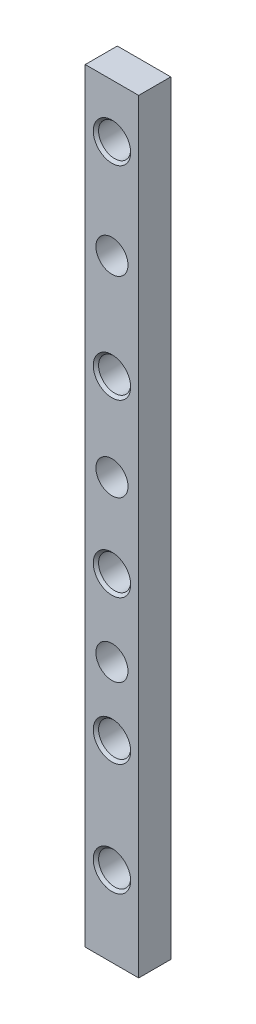
from build123d import *

# Parameters (mm, degrees)
SKETCH1_W           = 10
SKETCH1_H           = 143
SKETCH1_R           = 3
BOSS_EXTRUDE1_DEPTH = 6
CHAMFER1_SIZE       = 0.5


with BuildPart() as part:
    # Sketch1 → Boss-Extrude1 (new body)
    with BuildSketch(Plane.XY):
        Rectangle(SKETCH1_W, SKETCH1_H)
        with Locations((0, -56.5)):
            Circle(SKETCH1_R, mode=Mode.SUBTRACT)
        with Locations((0, -35.5)):
            Circle(SKETCH1_R, mode=Mode.SUBTRACT)
        with Locations((0, -8.5)):
            Circle(SKETCH1_R, mode=Mode.SUBTRACT)
        with Locations((0, 23.5)):
            Circle(SKETCH1_R, mode=Mode.SUBTRACT)
        with Locations((0, 61.5)):
            Circle(SKETCH1_R, mode=Mode.SUBTRACT)
        with Locations((0, 43.004767178)):
            Circle(SKETCH1_R, mode=Mode.SUBTRACT)
        with Locations((0, 7.137747133)):
            Circle(SKETCH1_R, mode=Mode.SUBTRACT)
        with Locations((0, -22.793294966)):
            Circle(SKETCH1_R, mode=Mode.SUBTRACT)
    extrude(amount=BOSS_EXTRUDE1_DEPTH)

    # Chamfer1
    chamfer1_edges = [part.edges().sort_by_distance(p)[0] for p in [
        (-3, -56.5, 6),
        (-3, -35.5, 6),
        (-3, -8.5, 6),
        (-3, 23.5, 6),
        (-3, 61.5, 6),
    ]]
    chamfer(chamfer1_edges, length=CHAMFER1_SIZE)


solid = part.part
